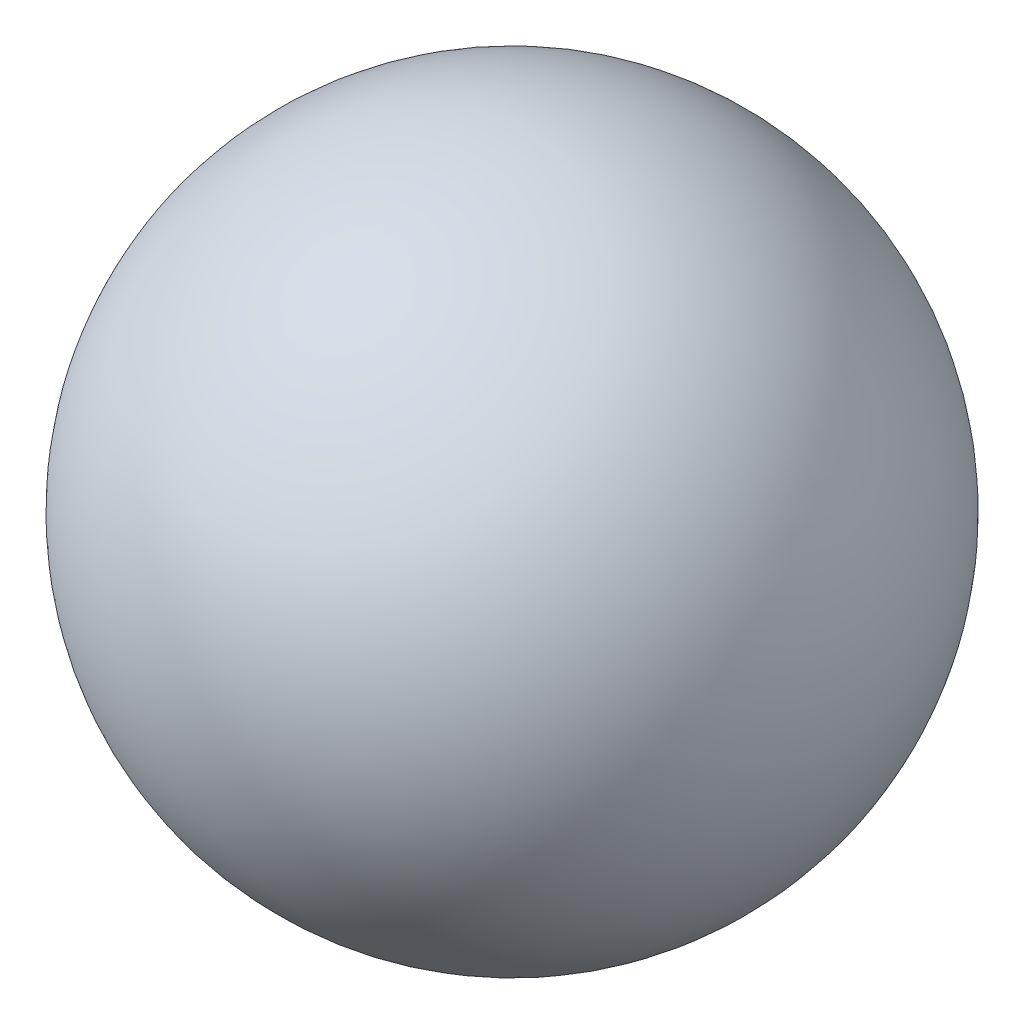
from build123d import *


with BuildPart() as part:
    # Sketch1 → Revolve1 (revolve)
    with BuildSketch(Plane.XY):
        with BuildLine():
            Line((-2.38125, 0), (2.38125, 0))
            ThreePointArc((2.38125, 0), (0, 2.38125), (-2.38125, 0))
        make_face()
    revolve(axis=Axis((0, 0, 0), (-1, 0, 0)))


solid = part.part
